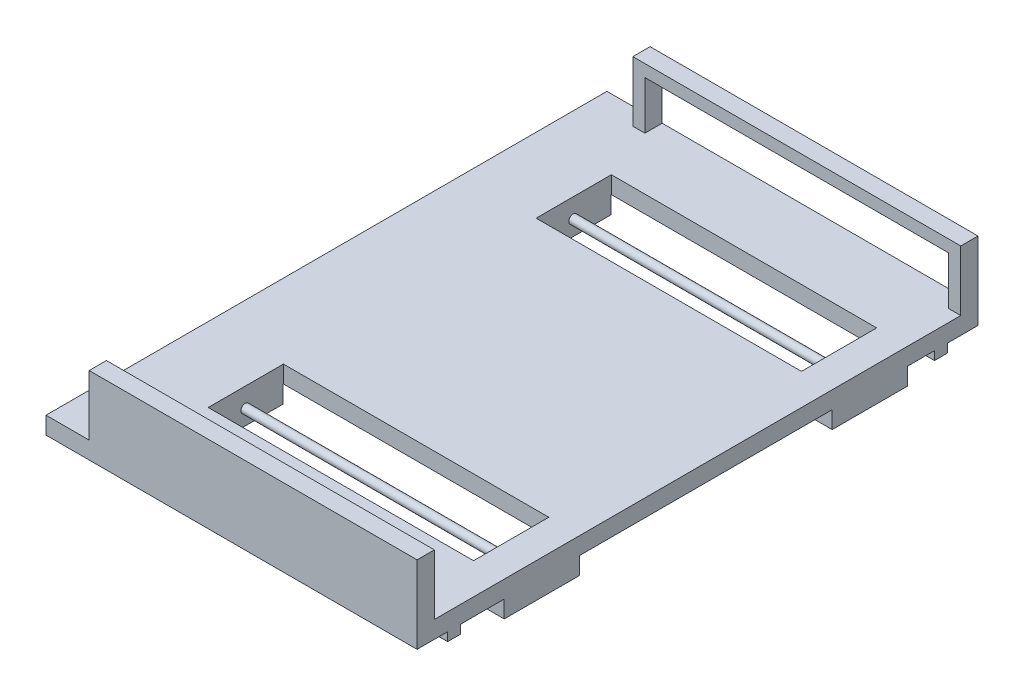
from build123d import *

# Parameters (mm, degrees)
SKETCH1_W           = 325
SKETCH1_H           = 10
SKETCH1_W_2         = 10
SKETCH1_H_2         = 34.925125471
BOSS_EXTRUDE1_DEPTH = 190
SKETCH2_W           = 190
SKETCH2_H           = 7.5
BOSS_EXTRUDE2_DEPTH = 5
SKETCH6_W           = 43.6
SKETCH6_H           = 10
BOSS_EXTRUDE4_DEPTH = 190
CUT_EXTRUDE1_START  = -45.92512547
SKETCH3_W           = 153.75
SKETCH3_H           = 43.596922071
CUT_EXTRUDE1_DEPTH  = 56.92512547
SKETCH4_R           = 2.5
BOSS_EXTRUDE3_DEPTH = 171.875
LPATTERN1_COUNT     = 2
LPATTERN1_PITCH     = 190
SKETCH7_W           = 176
SKETCH7_H           = 27.925125471
CUT_EXTRUDE5_DEPTH  = 315
SKETCH8_W           = 25
SKETCH8_H           = 10
BOSS_EXTRUDE6_DEPTH = 325


with BuildPart() as part:
    # Sketch1 → Boss-Extrude1 (new body)
    with BuildSketch(Plane(origin=(0, 0, 0), x_dir=(0, 0, -1), z_dir=(1, 0, 0))):
        with Locations((0, -9.857682562)):
            Rectangle(SKETCH1_W, SKETCH1_H)
        with Locations((-157.5, 12.604880173)):
            Rectangle(SKETCH1_W_2, SKETCH1_H_2)
        with Locations((157.5, 12.604880173)):
            Rectangle(SKETCH1_W_2, SKETCH1_H_2)
    extrude(amount=BOSS_EXTRUDE1_DEPTH)

    # Sketch2 → Boss-Extrude2 (add)
    with BuildSketch(Plane.XZ.offset(14.857682562)):
        with Locations((95, 141.030384385)):
            Rectangle(SKETCH2_W, SKETCH2_H)
        with Locations((95, -141.03)):
            Rectangle(SKETCH2_W, SKETCH2_H)
    extrude(amount=BOSS_EXTRUDE2_DEPTH)

    # Sketch6 → Boss-Extrude4 (add, through all)
    with BuildSketch(Plane.ZY):
        with Locations((90.204898917, -19.857682562)):
            Rectangle(SKETCH6_W, SKETCH6_H)
    boss_extrude4 = extrude(amount=-BOSS_EXTRUDE4_DEPTH)

    # Sketch3 → Cut-Extrude1 (cut)
    with BuildSketch(Plane.XZ.offset(14.857682562).offset(CUT_EXTRUDE1_START)):
        with Locations((95, 89.856251598)):
            Rectangle(SKETCH3_W, SKETCH3_H)
    cut_extrude1 = extrude(amount=CUT_EXTRUDE1_DEPTH, mode=Mode.SUBTRACT)

    # Sketch4 → Boss-Extrude3 (add, through all)
    with BuildSketch(Plane.ZY.offset(-171.875)):
        with Locations((90.207259337, -15.987312382)):
            Circle(SKETCH4_R)
    boss_extrude3 = extrude(amount=BOSS_EXTRUDE3_DEPTH)

    # LPattern1: Boss-Extrude4, Cut-Extrude1, Boss-Extrude3 ×2
    with Locations(*[(0, 0, -i * LPATTERN1_PITCH) for i in range(1, LPATTERN1_COUNT)]):
        add(boss_extrude4)
        add(cut_extrude1, mode=Mode.SUBTRACT)
        add(boss_extrude3)

    # Sketch7 → Cut-Extrude5 (cut)
    with BuildSketch(Plane(origin=(0, 0, 152.5), x_dir=(-1, 0, 0), z_dir=(0, 0, -1))):
        with Locations((-95, 9.104880173)):
            Rectangle(SKETCH7_W, SKETCH7_H)
    extrude(amount=CUT_EXTRUDE5_DEPTH, mode=Mode.SUBTRACT)

    # Sketch8 → Boss-Extrude6 (add)
    with BuildSketch(Plane(origin=(0, 0, -162.5), x_dir=(-1, 0, 0), z_dir=(0, 0, -1))):
        with Locations((12.5, -9.857682562)):
            Rectangle(SKETCH8_W, SKETCH8_H)
    extrude(amount=-BOSS_EXTRUDE6_DEPTH)


solid = part.part
